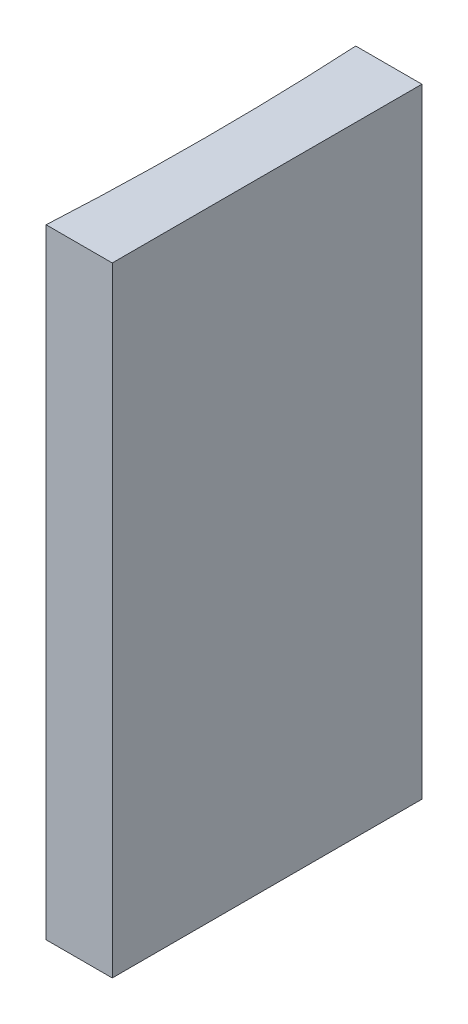
from build123d import *

# Parameters (mm, degrees)
EXTRUDE_1_DEPTH = 20


with BuildPart() as part:
    # 草图1 → 凸台-拉伸1 (new body)
    with BuildSketch(Plane(origin=(0, 0, 0), x_dir=(1, 0, 0), z_dir=(0, 1, 0))):
        with BuildLine():
            Line((0, 0), (0, -10))
            Line((0, -10), (-2.136415535, -10))
            ThreePointArc((-2.136415535, -10), (-2, -5), (-2.136415535, 0))
            Line((-2.136415535, 0), (0, 0))
        make_face()
    extrude(amount=EXTRUDE_1_DEPTH)


solid = part.part
